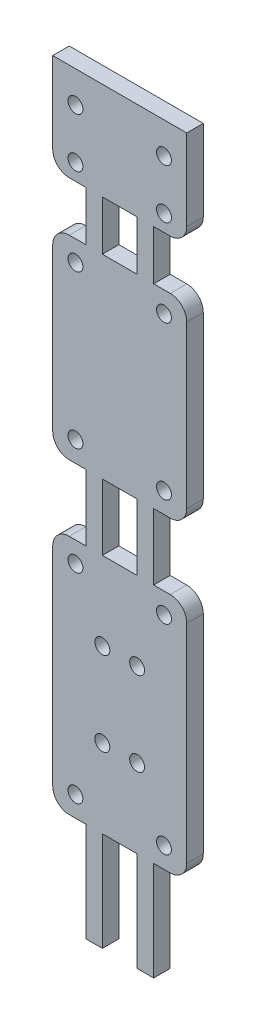
from build123d import *

# Parameters (mm, degrees)
SKETCH1_R           = 0.9
SKETCH1_W           = 4.2
SKETCH1_H           = 8
SKETCH1_H_2         = 6
BOSS_EXTRUDE1_DEPTH = 2


with BuildPart() as part:
    # Sketch1 → Boss-Extrude1 (new body)
    with BuildSketch(Plane.XY):
        with BuildLine():
            Line((4, 26), (2, 26))
            ThreePointArc((2, 26), (0.585786438, 26.585786438), (0, 28))
            Line((0, 28), (0, 53.14))
            ThreePointArc((0, 53.14), (0.585786438, 54.554213562), (2, 55.14))
            Line((2, 55.14), (4, 55.14))
            Line((4, 55.14), (4, 63.14))
            Line((4, 63.14), (2, 63.14))
            ThreePointArc((2, 63.14), (0.585786438, 63.725786438), (0, 65.14))
            Line((0, 65.14), (0, 84.665))
            ThreePointArc((0, 84.665), (0.585786438, 86.079213562), (2, 86.665))
            Line((2, 86.665), (4, 86.665))
            Line((4, 86.665), (4, 92.665))
            Line((4, 92.665), (2, 92.665))
            ThreePointArc((2, 92.665), (0.585786438, 93.250786438), (0, 94.665))
            Line((0, 94.665), (0, 104.46))
            Line((0, 104.46), (16.2, 104.46))
            Line((16.2, 104.46), (16.2, 94.665))
            ThreePointArc((16.2, 94.665), (15.614213562, 93.250786438), (14.2, 92.665))
            Line((14.2, 92.665), (12.2, 92.665))
            Line((12.2, 92.665), (12.2, 86.665))
            Line((12.2, 86.665), (14.2, 86.665))
            ThreePointArc((14.2, 86.665), (15.614213562, 86.079213562), (16.2, 84.665))
            Line((16.2, 84.665), (16.2, 65.14))
            ThreePointArc((16.2, 65.14), (15.614213562, 63.725786438), (14.2, 63.14))
            Line((14.2, 63.14), (12.2, 63.14))
            Line((12.2, 63.14), (12.2, 55.14))
            Line((12.2, 55.14), (14.2, 55.14))
            ThreePointArc((14.2, 55.14), (15.614213562, 54.554213562), (16.2, 53.14))
            Line((16.2, 53.14), (16.2, 28))
            ThreePointArc((16.2, 28), (15.614213562, 26.585786438), (14.2, 26))
            Line((14.2, 26), (12.2, 26))
            Line((12.2, 26), (12.2, 14))
            Line((12.2, 14), (10.2, 14))
            Line((10.2, 14), (10.2, 26))
            Line((10.2, 26), (6, 26))
            Line((6, 26), (6, 14))
            Line((6, 14), (4, 14))
            Line((4, 14), (4, 26))
        make_face()
        with Locations((13.45, 94.665)):
            Circle(SKETCH1_R, mode=Mode.SUBTRACT)
        with Locations((13.45, 84.165)):
            Circle(SKETCH1_R, mode=Mode.SUBTRACT)
        with Locations((13.45, 65.64)):
            Circle(SKETCH1_R, mode=Mode.SUBTRACT)
        with Locations((13.45, 52.64)):
            Circle(SKETCH1_R, mode=Mode.SUBTRACT)
        with Locations((13.45, 28.5)):
            Circle(SKETCH1_R, mode=Mode.SUBTRACT)
        with Locations((10.2, 35.5)):
            Circle(SKETCH1_R, mode=Mode.SUBTRACT)
        with Locations((10.2, 45.64)):
            Circle(SKETCH1_R, mode=Mode.SUBTRACT)
        with Locations((13.45, 100.665)):
            Circle(SKETCH1_R, mode=Mode.SUBTRACT)
        with Locations((2.75, 100.665)):
            Circle(SKETCH1_R, mode=Mode.SUBTRACT)
        with Locations((6, 45.64)):
            Circle(SKETCH1_R, mode=Mode.SUBTRACT)
        with Locations((6, 35.5)):
            Circle(SKETCH1_R, mode=Mode.SUBTRACT)
        with Locations((2.75, 28.5)):
            Circle(SKETCH1_R, mode=Mode.SUBTRACT)
        with Locations((2.75, 52.64)):
            Circle(SKETCH1_R, mode=Mode.SUBTRACT)
        with Locations((2.75, 65.64)):
            Circle(SKETCH1_R, mode=Mode.SUBTRACT)
        with Locations((2.75, 84.165)):
            Circle(SKETCH1_R, mode=Mode.SUBTRACT)
        with Locations((2.75, 94.665)):
            Circle(SKETCH1_R, mode=Mode.SUBTRACT)
        with Locations((8.1, 59.14)):
            Rectangle(SKETCH1_W, SKETCH1_H, mode=Mode.SUBTRACT)
        with Locations((8.1, 89.665)):
            Rectangle(SKETCH1_W, SKETCH1_H_2, mode=Mode.SUBTRACT)
    extrude(amount=BOSS_EXTRUDE1_DEPTH)


solid = part.part
